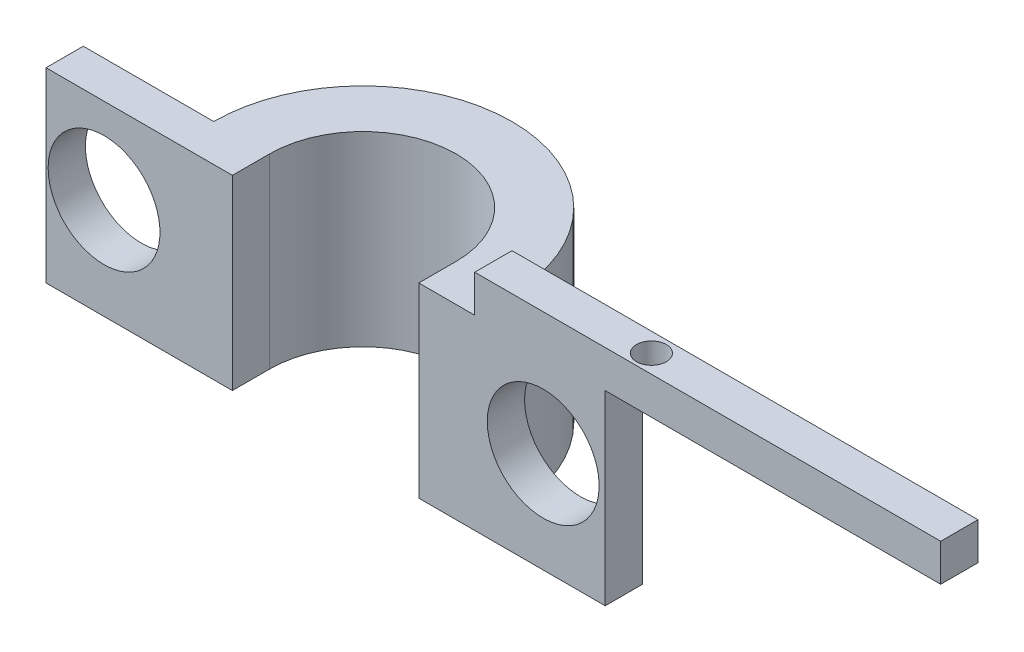
from build123d import *

# Parameters (mm, degrees)
SKETCH2_R           = 8
SKETCH2_R_2         = 5
EXTRUDE_THIN1_DEPTH = 10
CUT_EXTRUDE1_DEPTH  = 10
SKETCH4_W           = 10
SKETCH4_H           = 10
BOSS_EXTRUDE1_DEPTH = 2
SKETCH5_R           = 3
CUT_EXTRUDE2_DEPTH  = 2
SKETCH6_W           = 25
SKETCH6_H           = 2
BOSS_EXTRUDE2_DEPTH = 2
SKETCH7_R           = 0.8
CUT_EXTRUDE3_DEPTH  = 2


with BuildPart() as part:
    # Sketch2 → Extrude-Thin1 (new body)
    with BuildSketch(Plane(origin=(0, 0, 0), x_dir=(1, 0, 0), z_dir=(0, 1, 0))):
        Circle(SKETCH2_R)
        Circle(SKETCH2_R_2, mode=Mode.SUBTRACT)
    extrude(amount=EXTRUDE_THIN1_DEPTH)

    # Sketch3 → Cut-Extrude1 (cut)
    with BuildSketch(Plane(origin=(0, 10, 0), x_dir=(1, 0, 0), z_dir=(0, 1, 0))):
        with BuildLine():
            Line((-8, 0), (8, 0))
            ThreePointArc((8, 0), (0, -8), (-8, 0))
        make_face()
    extrude(amount=-CUT_EXTRUDE1_DEPTH, mode=Mode.SUBTRACT)

    # Sketch4 → Boss-Extrude1 (add)
    with BuildSketch(Plane.XY):
        with Locations((10, 5)):
            Rectangle(SKETCH4_W, SKETCH4_H)
        with Locations((-10, 5)):
            Rectangle(SKETCH4_W, SKETCH4_H)
    extrude(amount=BOSS_EXTRUDE1_DEPTH)

    # Sketch5 → Cut-Extrude2 (cut)
    with BuildSketch(Plane(origin=(0, 0, 0), x_dir=(-1, 0, 0), z_dir=(0, 0, -1))):
        with Locations((-11.674262076, 5.406814048)):
            Circle(SKETCH5_R)
        with Locations((11.885931395, 5.406814048)):
            Circle(SKETCH5_R)
    extrude(amount=-CUT_EXTRUDE2_DEPTH, mode=Mode.SUBTRACT)

    # Sketch6 → Boss-Extrude2 (add)
    with BuildSketch(Plane(origin=(0, 10, 0), x_dir=(1, 0, 0), z_dir=(0, 1, 0))):
        with Locations((20.5, -1)):
            Rectangle(SKETCH6_W, SKETCH6_H)
    extrude(amount=BOSS_EXTRUDE2_DEPTH)

    # Sketch7 → Cut-Extrude3 (cut)
    with BuildSketch(Plane(origin=(0, 12, 0), x_dir=(1, 0, 0), z_dir=(0, 1, 0))):
        with Locations((16.5, -1.021213906)):
            Circle(SKETCH7_R)
    extrude(amount=-CUT_EXTRUDE3_DEPTH, mode=Mode.SUBTRACT)


solid = part.part
